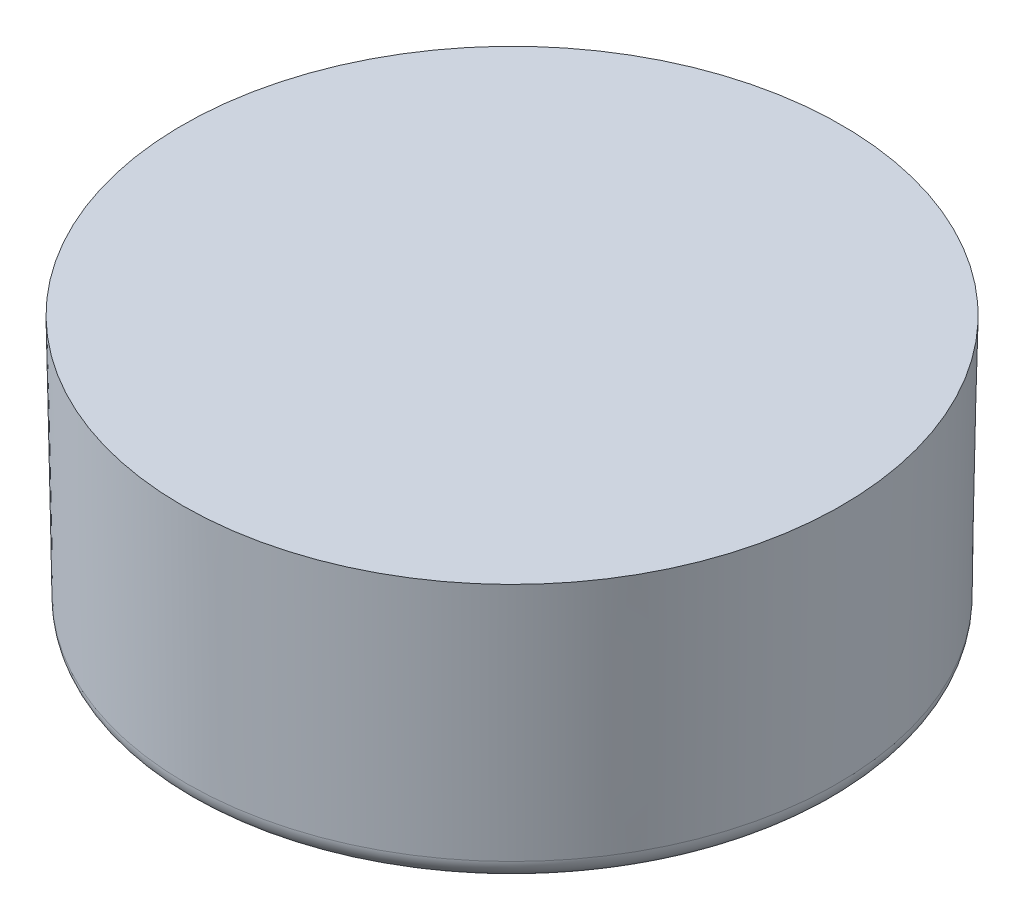
from build123d import *
from build123d.topology import SkipClean

# Parameters (mm, degrees)
SKETCH1_R           = 7.9375
BOSS_EXTRUDE1_DEPTH = 6.35
BOSS_EXTRUDE1_DRAFT = -1
CUT_EXTRUDE3_DEPTH  = 8.9375
CIRPATTERN3_COUNT   = 9
SKETCH7_R           = 7.9375
SKETCH7_R_2         = 5.5245
BOSS_EXTRUDE3_DEPTH = 6.35
BOSS_EXTRUDE3_DRAFT = -1
DRAFT1_ANGLE        = -10
FILLET2_R           = 0.508


with BuildPart() as part:
    # Sketch1 → Boss-Extrude1 (with draft: the straight prism first)
    with BuildSketch(Plane(origin=(0, 0, 0), x_dir=(1, 0, 0), z_dir=(0, 1, 0))):
        Circle(SKETCH1_R)
    extrude(amount=-BOSS_EXTRUDE1_DEPTH)
    # Boss-Extrude1: the draft: its side faces are tilted about the plane it starts from
    boss_extrude1_sides = [part.faces().sort_by_distance(p)[0] for p in [
        (-7.9375, -3.175, 0),
    ]]
    draft(boss_extrude1_sides, Plane(origin=(0, 0, 0), x_dir=(1, 0, 0), z_dir=(0, 1, 0)), BOSS_EXTRUDE1_DRAFT)

    # Sketch6 → Cut-Extrude3 (cut, through all)
    with BuildSketch(Plane.XY):
        Polygon((0, -2.413), (-7.112, -9.525), (7.112, -9.525), align=None)
    cut_extrude3 = extrude(amount=-CUT_EXTRUDE3_DEPTH, mode=Mode.SUBTRACT)

    # CirPattern3: Cut-Extrude3 ×9 about axis
    cirpattern3_axis = Axis((0, 0, 0), (0, 1, 0))
    for i in range(1, CIRPATTERN3_COUNT):
        add(cut_extrude3.rotate(cirpattern3_axis, i * 360 / CIRPATTERN3_COUNT), mode=Mode.SUBTRACT)


with BuildPart() as boss_extrude3_tool:
    # Sketch7 → Boss-Extrude3 (with draft: the straight prism first)
    with BuildSketch(Plane(origin=(0, 0, 0), x_dir=(1, 0, 0), z_dir=(0, 1, 0))):
        Circle(SKETCH7_R)
        Circle(SKETCH7_R_2, mode=Mode.SUBTRACT)
    extrude(amount=-BOSS_EXTRUDE3_DEPTH)
    # Boss-Extrude3: the draft: its side faces are tilted about the plane it starts from
    boss_extrude3_sides = [boss_extrude3_tool.faces().sort_by_distance(p)[0] for p in [
        (-7.9375, -3.175, 0),
        (-5.5245, -3.175, 0),
    ]]
    draft(boss_extrude3_sides, Plane(origin=(0, 0, 0), x_dir=(1, 0, 0), z_dir=(0, 1, 0)), BOSS_EXTRUDE3_DRAFT)


with BuildPart() as part_1:
    add(part.part)

    # Boss-Extrude3: add boss_extrude3_tool
    add(boss_extrude3_tool.part)

    # Draft1
    draft1_faces = [part_1.faces().sort_by_distance(p)[0] for p in [
        (-5.600979367, -4.381499996, 0),
    ]]
    draft(draft1_faces, Plane.ZX, DRAFT1_ANGLE)

    # Fillet2
    fillet2_edges = [part_1.edges().sort_by_distance(p)[0] for p in [
        (-7.826660338, -6.35, 0),
        (-6.644176327, -6.35, 0),
    ]]
    fillet(fillet2_edges, radius=FILLET2_R)

    # Sketch8 → Cut-Revolve1 (revolve, cut)
    with SkipClean():  # keep this step's faces unmerged: merging them makes the solid invalid here
        with BuildSketch(Plane(origin=(0, 0, 0), x_dir=(0, 0, -1), z_dir=(1, 0, 0))):
            with BuildLine():
                Line((-5.800063528, -2.413), (-5.800063528, -6.720189325))
                Line((-5.800063528, -6.720189325), (-6.570156602, -6.720189325))
                Line((-6.570156602, -6.720189325), (-6.570156602, -5.930213274))
                Line((-6.570156602, -5.930213274), (-5.949977004, -2.413))
                ThreePointArc((-5.949977004, -2.413), (-5.875020266, -2.350103828), (-5.800063528, -2.413))
            make_face()
        revolve(axis=Axis((0, 0, 0), (0, -1, 0)), mode=Mode.SUBTRACT)


solid = part_1.part
